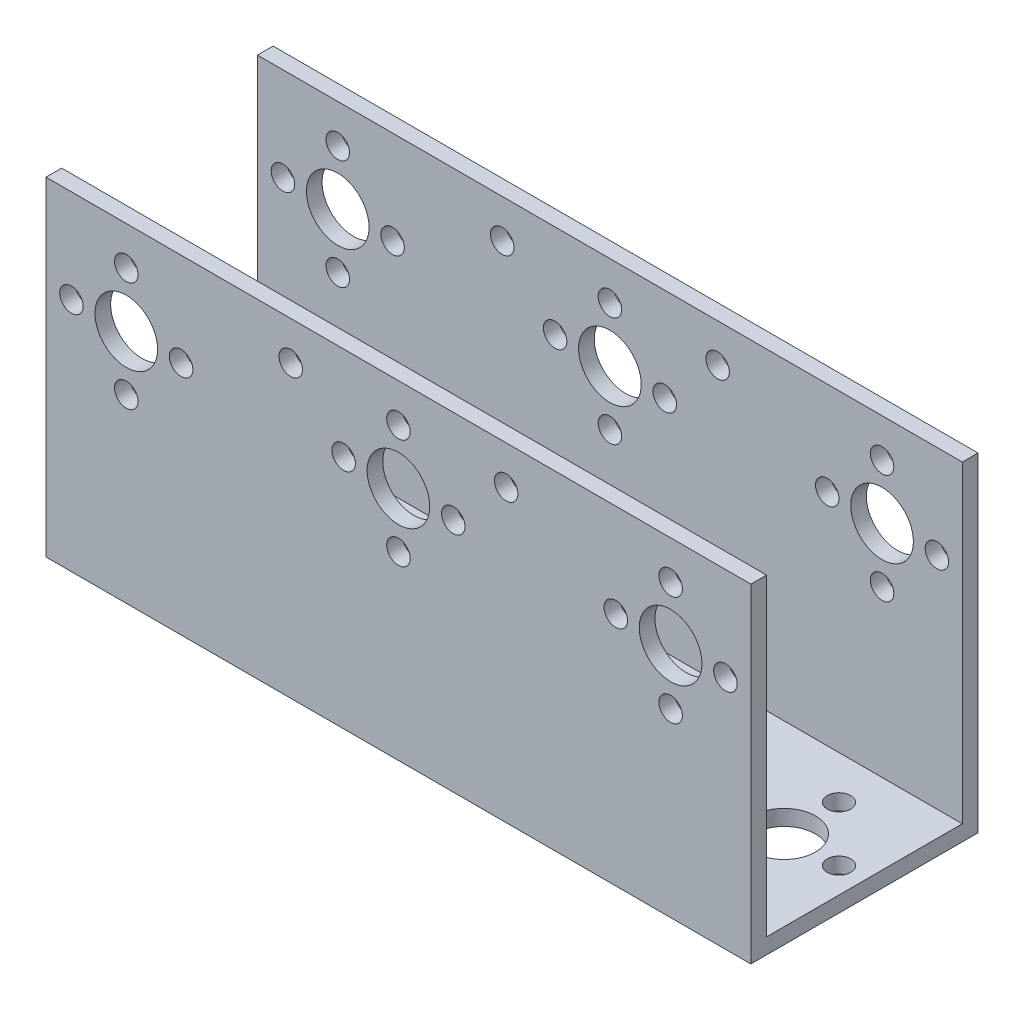
from build123d import *

# Parameters (mm, degrees)
SKETCH1_W           = 90
SKETCH1_H           = 25
SKETCH1_R           = 4
SKETCH1_R_2         = 1.5
BOSS_EXTRUDE1_DEPTH = 2
SKETCH2_W           = 90
SKETCH2_H           = 42
SKETCH2_R           = 4
SKETCH2_R_2         = 1.5
BOSS_EXTRUDE2_DEPTH = 2


with BuildPart() as part:
    # Sketch1 → Boss-Extrude1 (new body)
    with BuildSketch(Plane(origin=(0, 0, 0), x_dir=(1, 0, 0), z_dir=(0, 1, 0))):
        Rectangle(SKETCH1_W, SKETCH1_H)
        Circle(SKETCH1_R, mode=Mode.SUBTRACT)
        with Locations((34.75, 0)):
            Circle(SKETCH1_R, mode=Mode.SUBTRACT)
        with Locations((0, 7)):
            Circle(SKETCH1_R_2, mode=Mode.SUBTRACT)
        with Locations((7, 0)):
            Circle(SKETCH1_R_2, mode=Mode.SUBTRACT)
        with Locations((-7, 0)):
            Circle(SKETCH1_R_2, mode=Mode.SUBTRACT)
        with Locations((0, -7)):
            Circle(SKETCH1_R_2, mode=Mode.SUBTRACT)
        with Locations((-34.75, 0)):
            Circle(SKETCH1_R, mode=Mode.SUBTRACT)
        with Locations((34.75, 7)):
            Circle(SKETCH1_R_2, mode=Mode.SUBTRACT)
        with Locations((41.75, 0)):
            Circle(SKETCH1_R_2, mode=Mode.SUBTRACT)
        with Locations((34.75, -7)):
            Circle(SKETCH1_R_2, mode=Mode.SUBTRACT)
        with Locations((27.75, 0)):
            Circle(SKETCH1_R_2, mode=Mode.SUBTRACT)
        with Locations((-34.75, 7)):
            Circle(SKETCH1_R_2, mode=Mode.SUBTRACT)
        with Locations((-27.75, 0)):
            Circle(SKETCH1_R_2, mode=Mode.SUBTRACT)
        with Locations((-34.75, -7)):
            Circle(SKETCH1_R_2, mode=Mode.SUBTRACT)
        with Locations((-41.75, 0)):
            Circle(SKETCH1_R_2, mode=Mode.SUBTRACT)
    extrude(amount=BOSS_EXTRUDE1_DEPTH)

    # Sketch2 → Boss-Extrude2 (add)
    with BuildSketch(Plane.XY.offset(12.5)):
        with Locations((0, 21)):
            Rectangle(SKETCH2_W, SKETCH2_H)
        with Locations((0, 30.08)):
            Circle(SKETCH2_R, mode=Mode.SUBTRACT)
        with Locations((0, 37.08)):
            Circle(SKETCH2_R_2, mode=Mode.SUBTRACT)
        with Locations((7, 30.08)):
            Circle(SKETCH2_R_2, mode=Mode.SUBTRACT)
        with Locations((0, 23.08)):
            Circle(SKETCH2_R_2, mode=Mode.SUBTRACT)
        with Locations((-7, 30.08)):
            Circle(SKETCH2_R_2, mode=Mode.SUBTRACT)
        with Locations((34.75, 30.08)):
            Circle(SKETCH2_R, mode=Mode.SUBTRACT)
        with Locations((34.75, 37.08)):
            Circle(SKETCH2_R_2, mode=Mode.SUBTRACT)
        with Locations((41.75, 30.08)):
            Circle(SKETCH2_R_2, mode=Mode.SUBTRACT)
        with Locations((34.75, 23.08)):
            Circle(SKETCH2_R_2, mode=Mode.SUBTRACT)
        with Locations((27.75, 30.08)):
            Circle(SKETCH2_R_2, mode=Mode.SUBTRACT)
        with Locations((-34.75, 30.08)):
            Circle(SKETCH2_R, mode=Mode.SUBTRACT)
        with Locations((-34.75, 37.08)):
            Circle(SKETCH2_R_2, mode=Mode.SUBTRACT)
        with Locations((-27.75, 30.08)):
            Circle(SKETCH2_R_2, mode=Mode.SUBTRACT)
        with Locations((-34.75, 23.08)):
            Circle(SKETCH2_R_2, mode=Mode.SUBTRACT)
        with Locations((-41.75, 30.08)):
            Circle(SKETCH2_R_2, mode=Mode.SUBTRACT)
        with Locations((13.75, 37.08)):
            Circle(SKETCH2_R_2, mode=Mode.SUBTRACT)
        with Locations((-13.75, 37.08)):
            Circle(SKETCH2_R_2, mode=Mode.SUBTRACT)
    extrude(amount=BOSS_EXTRUDE2_DEPTH)

    # Mirror1: part across plane


with BuildPart() as part_1:
    add(part.part)
    add(part.part.mirror(Plane.XY))


solid = part_1.part
